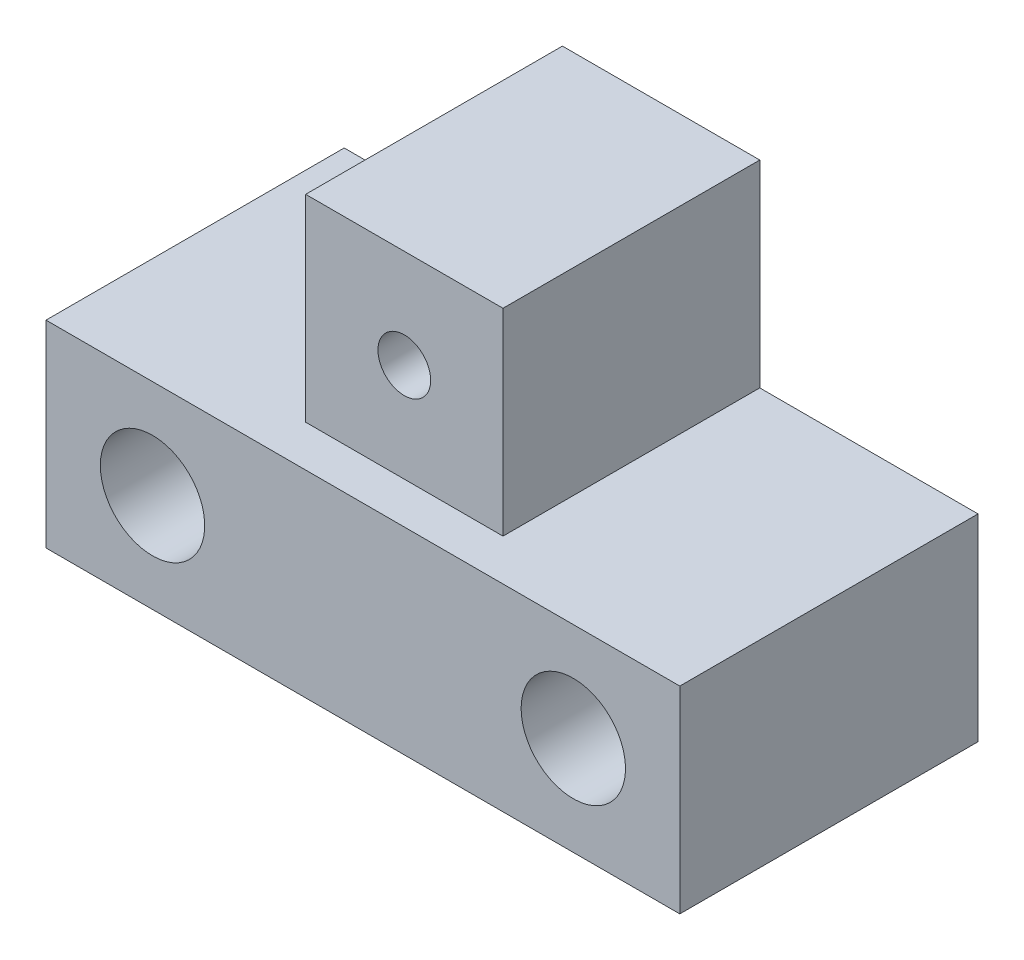
from build123d import *

# Parameters (mm, degrees)
SKETCH1_R           = 0.795
BOSS_EXTRUDE1_DEPTH = 9
SKETCH4_W           = 1.25
SKETCH4_H           = 5.95656864
CUT_EXTRUDE2_DEPTH  = 13.54328432
SKETCH5_R           = 1.575
CUT_EXTRUDE3_DEPTH  = 10


with BuildPart() as part:
    # Sketch1 → Boss-Extrude1 (new body)
    with BuildSketch(Plane.XY):
        Polygon((0, 0), (0, 5.95656864), (6.58671568, 5.95656864), (6.58671568, 11.91313728), (12.54328432, 11.91313728), (12.54328432, 5.95656864), (19.13, 5.95656864), (19.13, 0), align=None)
        with Locations((9.565, 8.93485296)):
            Circle(SKETCH1_R, mode=Mode.SUBTRACT)
    extrude(amount=BOSS_EXTRUDE1_DEPTH)

    # Sketch4 → Cut-Extrude2 (cut, through all)
    with BuildSketch(Plane(origin=(12.54328432, 0, 0), x_dir=(0, 0, -1), z_dir=(1, 0, 0))):
        with Locations((-8.375, 8.93485296)):
            Rectangle(SKETCH4_W, SKETCH4_H)
    extrude(amount=-CUT_EXTRUDE2_DEPTH, mode=Mode.SUBTRACT)

    # Sketch5 → Cut-Extrude3 (cut, through all)
    with BuildSketch(Plane(origin=(0, 0, 0), x_dir=(-1, 0, 0), z_dir=(0, 0, -1))):
        with Locations((-3.215, 2.97828432)):
            Circle(SKETCH5_R)
        with Locations((-15.915, 2.97828432)):
            Circle(SKETCH5_R)
    extrude(amount=-CUT_EXTRUDE3_DEPTH, mode=Mode.SUBTRACT)


solid = part.part
